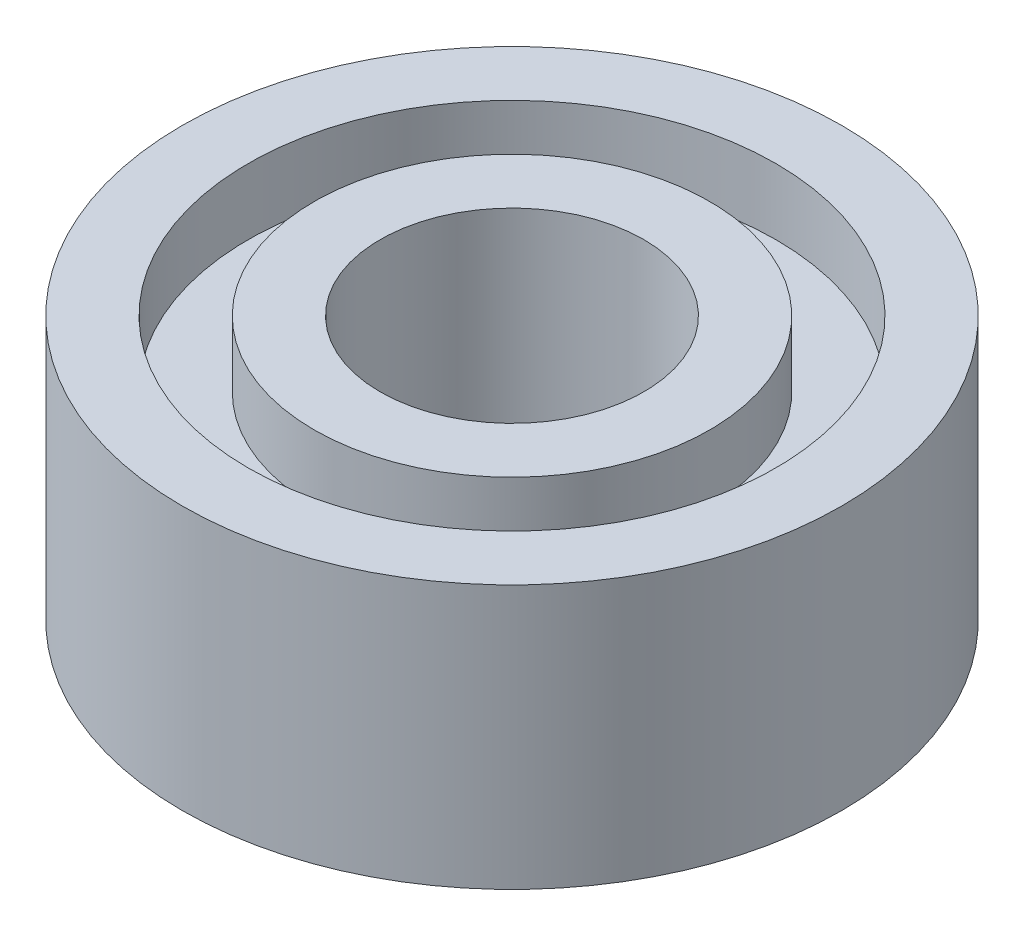
from build123d import *

# Parameters (mm, degrees)
SKETCH1_R           = 5
SKETCH1_R_2         = 2
BOSS_EXTRUDE1_DEPTH = 4
SKETCH2_R           = 4
SKETCH2_R_2         = 3
CUT_EXTRUDE1_DEPTH  = 1
SKETCH3_R           = 4
SKETCH3_R_2         = 3
CUT_EXTRUDE2_DEPTH  = 1


with BuildPart() as part:
    # Sketch1 → Boss-Extrude1 (new body)
    with BuildSketch(Plane(origin=(0, 0, 0), x_dir=(1, 0, 0), z_dir=(0, 1, 0))):
        Circle(SKETCH1_R)
        Circle(SKETCH1_R_2, mode=Mode.SUBTRACT)
    extrude(amount=BOSS_EXTRUDE1_DEPTH)

    # Sketch2 → Cut-Extrude1 (cut)
    with BuildSketch(Plane(origin=(0, 4, 0), x_dir=(1, 0, 0), z_dir=(0, 1, 0))):
        Circle(SKETCH2_R)
        Circle(SKETCH2_R_2, mode=Mode.SUBTRACT)
    extrude(amount=-CUT_EXTRUDE1_DEPTH, mode=Mode.SUBTRACT)

    # Sketch3 → Cut-Extrude2 (cut)
    with BuildSketch(Plane.XZ):
        Circle(SKETCH3_R)
        Circle(SKETCH3_R_2, mode=Mode.SUBTRACT)
    extrude(amount=-CUT_EXTRUDE2_DEPTH, mode=Mode.SUBTRACT)


solid = part.part
